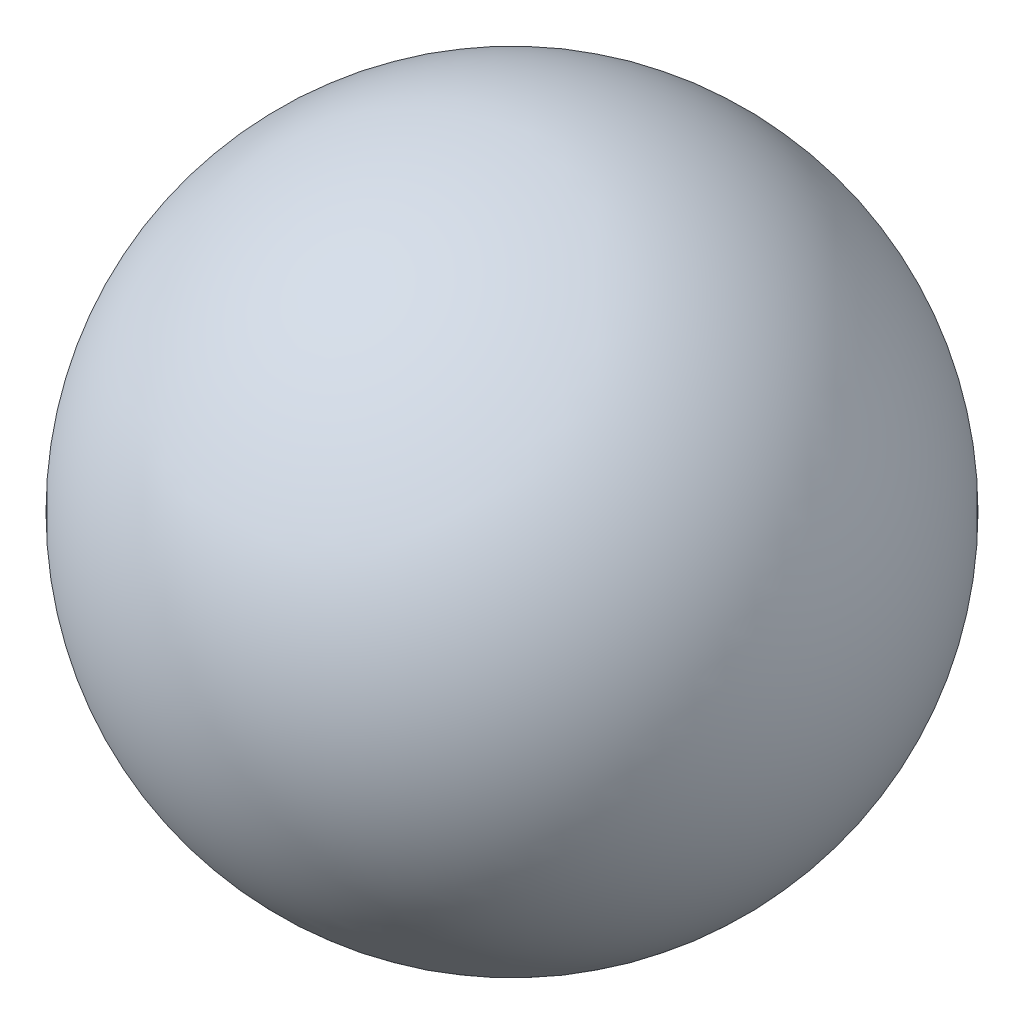
from build123d import *


with BuildPart() as part:
    # Sketch1 → Revolve1 (revolve)
    with BuildSketch(Plane(origin=(0, 0, 0), x_dir=(1, 0, 0), z_dir=(0, 1, 0))):
        with BuildLine():
            Line((0, 0), (15.086830283, 15.086830283))
            ThreePointArc((15.086830283, 15.086830283), (15.086830283, -15.086830283), (-15.086830283, -15.086830283))
            Line((-15.086830283, -15.086830283), (0, 0))
        make_face()
    revolve(axis=Axis((0, 0, 0), (0.707106781, 0, -0.707106781)))


solid = part.part
